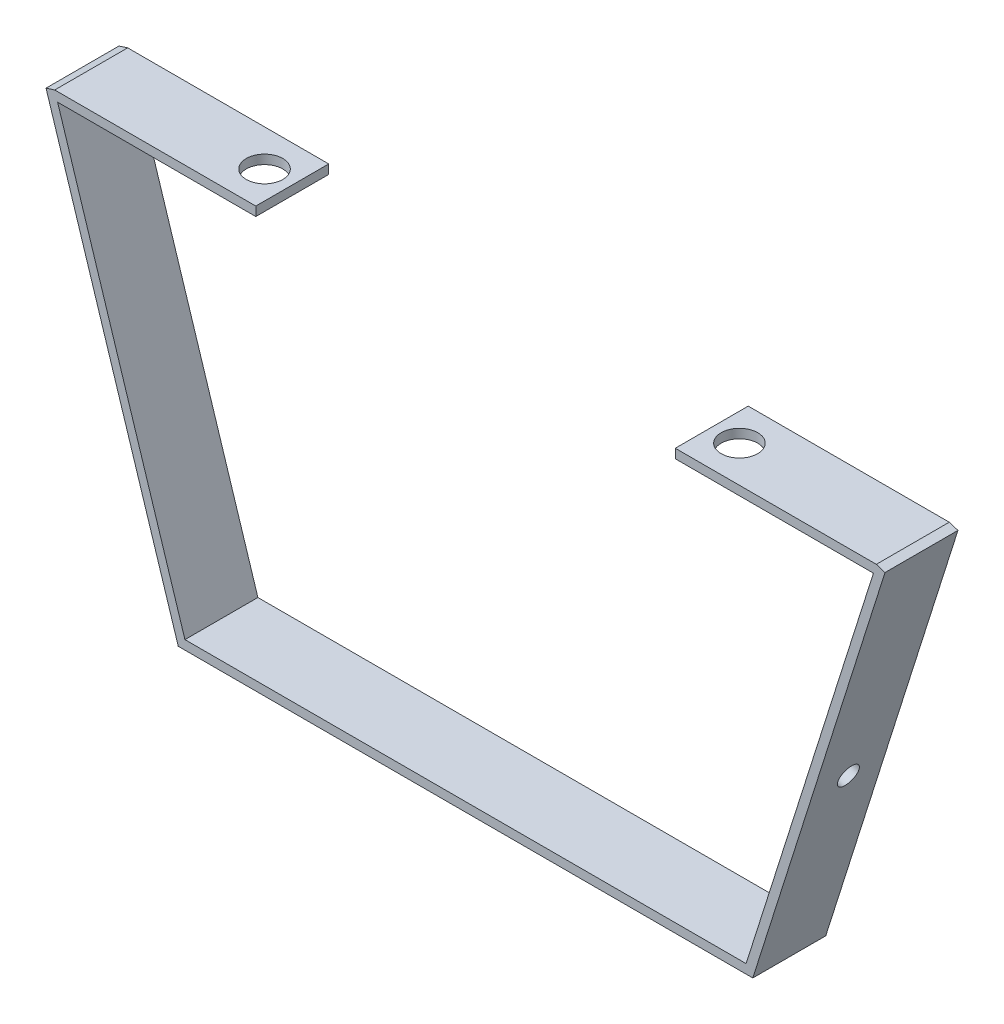
from build123d import *

# Parameters (mm, degrees)
BOSS_EXTRUDE1_DEPTH = 25.4
BOSS_EXTRUDE2_DEPTH = 25.4
SKETCH6_R           = 6.35
CUT_EXTRUDE1_DEPTH  = 10
SKETCH7_R           = 3.675
CUT_EXTRUDE2_DEPTH  = 3.175


with BuildPart() as part:
    # Sketch1 → Boss-Extrude1 (new body)
    with BuildSketch(Plane.XY):
        Polygon((-95.914729745, -24.450906393), (104.110270255, -24.450906393), (150.147770255, 120.829197523), (147.121101424, 121.788312106), (101.785788593, -21.275906393), (-93.590248082, -21.275906393), (-138.925560913, 121.788312106), (-141.952229745, 120.829197523), align=None)
    extrude(amount=BOSS_EXTRUDE1_DEPTH)

    # Sketch4 → Boss-Extrude2 (add)
    with BuildSketch(Plane(origin=(0, 0, 0), x_dir=(-1, 0, 0), z_dir=(0, 0, -1))):
        Polygon((-77.121101424, 121.788312106), (-147.121101424, 121.788312106), (-150.147770255, 120.829197523), (-146.114982495, 118.613312106), (-77.121101424, 118.613312106), align=None)
        Polygon((138.925560913, 121.788312106), (68.925560913, 121.788312106), (68.925560913, 118.613312106), (137.919441985, 118.613312106), (141.952229745, 120.829197523), align=None)
    extrude(amount=-BOSS_EXTRUDE2_DEPTH)

    # Sketch6 → Cut-Extrude1 (cut)
    with BuildSketch(Plane(origin=(0, 121.788312106, 0), x_dir=(1, 0, 0), z_dir=(0, 1, 0))):
        with Locations((-78.575560913, -12.7)):
            Circle(SKETCH6_R)
        with Locations((86.771101424, -12.7)):
            Circle(SKETCH6_R)
    extrude(amount=-CUT_EXTRUDE1_DEPTH, mode=Mode.SUBTRACT)

    # Sketch7 → Cut-Extrude2 (cut)
    with BuildSketch(Plane(origin=(101.650894981, -32.211933717, 0), x_dir=(0, 0, -1), z_dir=(0.953281522, -0.302083333, 0))):
        with Locations((-12.7, 76.285872314)):
            Circle(SKETCH7_R)
    extrude(amount=-CUT_EXTRUDE2_DEPTH, mode=Mode.SUBTRACT)


solid = part.part
